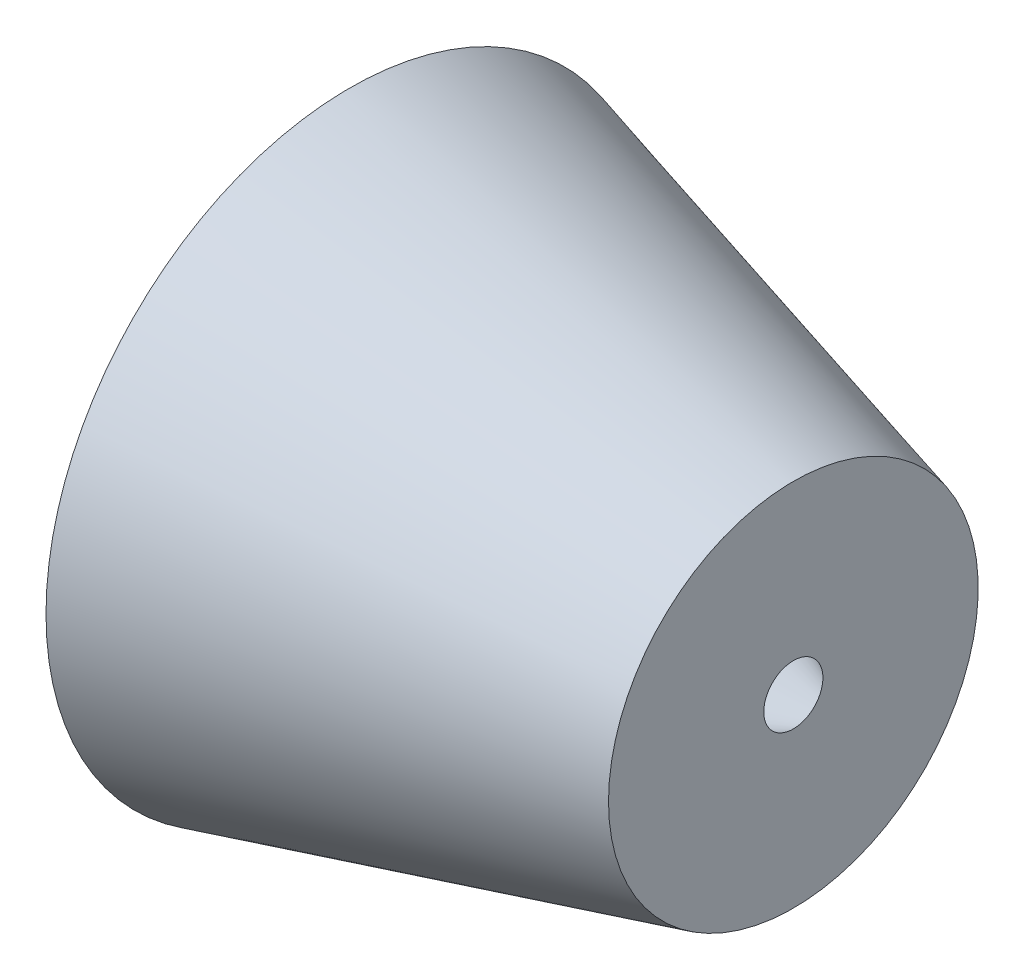
from build123d import *

# Parameters (mm, degrees)
SKETCH4_R           = 12.5
BOSS_EXTRUDE5_DEPTH = 30
BOSS_EXTRUDE5_TAPER = -15
SKETCH4_3_R         = 2
CUT_EXTRUDE2_DEPTH  = 30
CUT_EXTRUDE2_TAPER  = -25


with BuildPart() as part:
    # Sketch4 → Boss-Extrude5 (new body)
    with BuildSketch(Plane.ZY):
        Circle(SKETCH4_R)
    extrude(amount=BOSS_EXTRUDE5_DEPTH, taper=BOSS_EXTRUDE5_TAPER)

    # Sketch4_3 → Cut-Extrude2 (cut)
    with BuildSketch(Plane.ZY):
        Circle(SKETCH4_3_R)
    extrude(amount=CUT_EXTRUDE2_DEPTH, taper=CUT_EXTRUDE2_TAPER, mode=Mode.SUBTRACT)


solid = part.part
